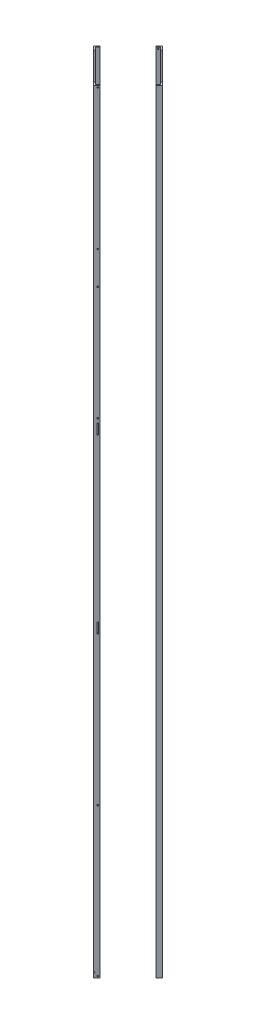
from build123d import *

# Parameters (mm, degrees)
BOSS_EXTRUDE1_DEPTH   = 2133.6
BOSS_EXTRUDE1_2_DEPTH = 2133.6
BOSS_EXTRUDE1_3_DEPTH = 2133.6
BOSS_EXTRUDE1_4_DEPTH = 2133.6
CUT_EXTRUDE1_DEPTH    = 3.175
CUT_EXTRUDE2_DEPTH    = 3.175
CUT_EXTRUDE3_DEPTH    = 3.175
CUT_EXTRUDE4_DEPTH    = 3.175
LPATTERN1_COUNT       = 2
LPATTERN1_PITCH       = 408.305
LPATTERN2_COUNT       = 2
LPATTERN2_PITCH       = 831.85
CUT_EXTRUDE5_DEPTH    = 3.175
CUT_EXTRUDE6_DEPTH    = 3.175
CUT_EXTRUDE7_DEPTH    = 3.175
CUT_EXTRUDE8_DEPTH    = 3.175
LPATTERN12_COUNT      = 2
LPATTERN12_PITCH      = 1308.1
LPATTERN13_COUNT      = 2
LPATTERN13_PITCH      = 476.25
LPATTERN16_COUNT      = 2
LPATTERN16_PITCH      = 1647.825
LPATTERN17_COUNT      = 2
LPATTERN17_PITCH      = 1333.5
LPATTERN18_COUNT      = 2
LPATTERN18_PITCH      = 1737.995
LPATTERN19_COUNT      = 2
LPATTERN19_PITCH      = 2124.075
SKETCH13_R            = 2.032
CUT_EXTRUDE9_DEPTH    = 12.225320151


with BuildPart() as part:
    # Sketch2 → Boss-Extrude1 (new body)
    with BuildSketch(Plane(origin=(0, 0, 0), x_dir=(1, 0, 0), z_dir=(0, 1, 0))):
        Polygon((0, 94.77428536), (-8.980256121, 85.794029239), (-6.735192091, 83.548965209), (0, 90.2841573), (6.735192091, 83.548965209), (8.980256121, 85.794029239), align=None)
    extrude(amount=BOSS_EXTRUDE1_DEPTH)

    # Sketch5 → Cut-Extrude2 (cut)
    with BuildSketch(Plane(origin=(-47.38714268, 0, -47.38714268), x_dir=(-0.707106781, 0, 0.707106781), z_dir=(-0.707106781, 0, -0.707106781))):
        with BuildLine():
            ThreePointArc((-57.32543986, 4.7625), (-59.07803986, 6.5151), (-60.83063986, 4.7625))
            Line((-60.83063986, 4.7625), (-57.32543986, 4.7625))
        make_face()
        with BuildLine():
            Line((-57.32543986, 4.7625), (-60.83063986, 4.7625))
            ThreePointArc((-60.83063986, 4.7625), (-59.07803986, 3.0099), (-57.32543986, 4.7625))
        make_face()
    cut_extrude2 = extrude(amount=-CUT_EXTRUDE2_DEPTH, mode=Mode.SUBTRACT)


with BuildPart() as body_2:
    # Sketch2 → Boss-Extrude1 2 (new body)
    with BuildSketch(Plane(origin=(0, 0, 0), x_dir=(1, 0, 0), z_dir=(0, 1, 0))):
        Polygon((94.741702077, 0.032583283), (85.761445956, 9.012839404), (83.516381926, 6.767775374), (90.251574017, 0.032583283), (83.516381926, -6.702608808), (85.761445956, -8.947672838), align=None)
    extrude(amount=BOSS_EXTRUDE1_2_DEPTH)

    # Sketch6 → Cut-Extrude3 (cut)
    with BuildSketch(Plane(origin=(47.38714268, 0, -47.38714268), x_dir=(-0.707106781, 0, -0.707106781), z_dir=(0.707106781, 0, -0.707106781))):
        with BuildLine():
            ThreePointArc((-57.27936014, 4.7625), (-59.03196014, 6.5151), (-60.78456014, 4.7625))
            Line((-60.78456014, 4.7625), (-57.27936014, 4.7625))
        make_face()
        with BuildLine():
            Line((-57.27936014, 4.7625), (-60.78456014, 4.7625))
            ThreePointArc((-60.78456014, 4.7625), (-59.03196014, 3.0099), (-57.27936014, 4.7625))
        make_face()
    cut_extrude3 = extrude(amount=-CUT_EXTRUDE3_DEPTH, mode=Mode.SUBTRACT)


with BuildPart() as body_3:
    # Sketch2 → Boss-Extrude1 3 (new body)
    with BuildSketch(Plane(origin=(0, 0, 0), x_dir=(1, 0, 0), z_dir=(0, 1, 0))):
        Polygon((0, -94.709118794), (8.980256121, -85.728862673), (6.735192091, -83.483798643), (0, -90.218990734), (-6.735192091, -83.483798643), (-8.980256121, -85.728862673), align=None)
    extrude(amount=BOSS_EXTRUDE1_3_DEPTH)

    # Sketch7 → Cut-Extrude4 (cut)
    with BuildSketch(Plane(origin=(47.354559397, 0, 47.354559397), x_dir=(0.707106781, 0, -0.707106781), z_dir=(0.707106781, 0, 0.707106781))):
        with BuildLine():
            ThreePointArc((-57.27936014, 4.7625), (-59.03196014, 6.5151), (-60.78456014, 4.7625))
            Line((-60.78456014, 4.7625), (-57.27936014, 4.7625))
        make_face()
        with BuildLine():
            Line((-57.27936014, 4.7625), (-60.78456014, 4.7625))
            ThreePointArc((-60.78456014, 4.7625), (-59.03196014, 3.0099), (-57.27936014, 4.7625))
        make_face()
    cut_extrude4 = extrude(amount=-CUT_EXTRUDE4_DEPTH, mode=Mode.SUBTRACT)


with BuildPart() as body_4:
    # Sketch2 → Boss-Extrude1 4 (new body)
    with BuildSketch(Plane(origin=(0, 0, 0), x_dir=(1, 0, 0), z_dir=(0, 1, 0))):
        Polygon((-94.741702077, 0.032583283), (-85.761445956, -8.947672838), (-83.516381926, -6.702608808), (-90.251574017, 0.032583283), (-83.516381926, 6.767775374), (-85.761445956, 9.012839404), align=None)
    extrude(amount=BOSS_EXTRUDE1_4_DEPTH)

    # Sketch4 → Cut-Extrude1 (cut)
    with BuildSketch(Plane(origin=(-47.354559397, 0, 47.354559397), x_dir=(0.707106781, 0, 0.707106781), z_dir=(-0.707106781, 0, 0.707106781))):
        with BuildLine():
            ThreePointArc((-60.83063986, 4.7625), (-59.07803986, 3.0099), (-57.32543986, 4.7625))
            Line((-57.32543986, 4.7625), (-60.83063986, 4.7625))
        make_face()
        with BuildLine():
            Line((-60.83063986, 4.7625), (-57.32543986, 4.7625))
            ThreePointArc((-57.32543986, 4.7625), (-59.07803986, 6.5151), (-60.83063986, 4.7625))
        make_face()
    cut_extrude1 = extrude(amount=-CUT_EXTRUDE1_DEPTH, mode=Mode.SUBTRACT)


with BuildPart() as lpattern1_tool:
    # LPattern1: Cut-Extrude1, Cut-Extrude2, Cut-Extrude3, Cut-Extrude4 ×2
    with Locations(*[(0, i * LPATTERN1_PITCH, 0) for i in range(1, LPATTERN1_COUNT)]):
        add(cut_extrude1)
        add(cut_extrude2)
        add(cut_extrude3)
        add(cut_extrude4)


with BuildPart() as part_1:
    add(part.part)

    # LPattern1: cut by lpattern1_tool
    add(lpattern1_tool.part, mode=Mode.SUBTRACT)


with BuildPart() as body_2_1:
    add(body_2.part)

    # LPattern1: cut by lpattern1_tool
    add(lpattern1_tool.part, mode=Mode.SUBTRACT)


with BuildPart() as body_3_1:
    add(body_3.part)

    # LPattern1: cut by lpattern1_tool
    add(lpattern1_tool.part, mode=Mode.SUBTRACT)


with BuildPart() as body_4_1:
    add(body_4.part)

    # LPattern1: cut by lpattern1_tool
    add(lpattern1_tool.part, mode=Mode.SUBTRACT)


with BuildPart() as lpattern2_tool:
    # LPattern2: Cut-Extrude1, Cut-Extrude2, Cut-Extrude3, Cut-Extrude4 ×2
    with Locations(*[(0, i * LPATTERN2_PITCH, 0) for i in range(1, LPATTERN2_COUNT)]):
        add(cut_extrude1)
        add(cut_extrude2)
        add(cut_extrude3)
        add(cut_extrude4)


with BuildPart() as part_2:
    add(part_1.part)

    # LPattern2: cut by lpattern2_tool
    add(lpattern2_tool.part, mode=Mode.SUBTRACT)

    # Sketch10 → Cut-Extrude7 (cut)
    with BuildSketch(Plane(origin=(-47.38714268, 0, -47.38714268), x_dir=(-0.707106781, 0, 0.707106781), z_dir=(-0.707106781, 0, -0.707106781))):
        with BuildLine():
            ThreePointArc((-60.83063986, 849.3125), (-59.07803986, 851.0651), (-57.32543986, 849.3125))
            Line((-57.32543986, 849.3125), (-60.83063986, 849.3125))
        make_face()
        with BuildLine():
            Line((-60.83063986, 849.3125), (-60.83063986, 836.6125))
            ThreePointArc((-60.83063986, 836.6125), (-59.07803986, 838.3651), (-57.32543986, 836.6125))
            Line((-57.32543986, 836.6125), (-57.32543986, 849.3125))
            Line((-57.32543986, 849.3125), (-60.83063986, 849.3125))
        make_face()
        with BuildLine():
            Line((-60.83063986, 836.6125), (-60.83063986, 823.9125))
            Line((-60.83063986, 823.9125), (-57.32543986, 823.9125))
            Line((-57.32543986, 823.9125), (-57.32543986, 836.6125))
            ThreePointArc((-57.32543986, 836.6125), (-59.07803986, 834.8599), (-60.83063986, 836.6125))
        make_face()
        with BuildLine():
            Line((-60.83063986, 823.9125), (-57.32543986, 823.9125))
            ThreePointArc((-57.32543986, 823.9125), (-59.07803986, 822.1599), (-60.83063986, 823.9125))
        make_face()
    cut_extrude7 = extrude(amount=-CUT_EXTRUDE7_DEPTH, mode=Mode.SUBTRACT)


with BuildPart() as body_2_2:
    add(body_2_1.part)

    # LPattern2: cut by lpattern2_tool
    add(lpattern2_tool.part, mode=Mode.SUBTRACT)

    # Sketch11 → Cut-Extrude8 (cut)
    with BuildSketch(Plane(origin=(47.38714268, 0, -47.38714268), x_dir=(-0.707106781, 0, -0.707106781), z_dir=(0.707106781, 0, -0.707106781))):
        with BuildLine():
            ThreePointArc((-60.78456014, 849.3125), (-59.03196014, 851.0651), (-57.27936014, 849.3125))
            Line((-57.27936014, 849.3125), (-60.78456014, 849.3125))
        make_face()
        with BuildLine():
            Line((-60.78456014, 849.3125), (-60.78456014, 836.612500003))
            ThreePointArc((-60.78456014, 836.612500003), (-59.031960138, 838.3651), (-57.27936014, 836.6125))
            Line((-57.27936014, 836.6125), (-57.27936014, 849.3125))
            Line((-57.27936014, 849.3125), (-60.78456014, 849.3125))
        make_face()
        with BuildLine():
            Line((-60.78456014, 836.612500003), (-60.78456014, 823.9125))
            Line((-60.78456014, 823.9125), (-57.27936014, 823.9125))
            Line((-57.27936014, 823.9125), (-57.27936014, 836.6125))
            ThreePointArc((-57.27936014, 836.6125), (-59.031960141, 834.8599), (-60.78456014, 836.612500003))
        make_face()
        with BuildLine():
            Line((-60.78456014, 823.9125), (-57.27936014, 823.9125))
            ThreePointArc((-57.27936014, 823.9125), (-59.03196014, 822.1599), (-60.78456014, 823.9125))
        make_face()
    cut_extrude8 = extrude(amount=-CUT_EXTRUDE8_DEPTH, mode=Mode.SUBTRACT)


with BuildPart() as body_3_2:
    add(body_3_1.part)

    # LPattern2: cut by lpattern2_tool
    add(lpattern2_tool.part, mode=Mode.SUBTRACT)

    # Sketch8 → Cut-Extrude5 (cut)
    with BuildSketch(Plane(origin=(47.354559397, 0, 47.354559397), x_dir=(0.707106781, 0, -0.707106781), z_dir=(0.707106781, 0, 0.707106781))):
        with BuildLine():
            ThreePointArc((-60.78456014, 849.3125), (-59.03196014, 851.0651), (-57.27936014, 849.3125))
            Line((-57.27936014, 849.3125), (-60.78456014, 849.3125))
        make_face()
        with BuildLine():
            Line((-60.78456014, 849.3125), (-60.78456014, 836.6125))
            ThreePointArc((-60.78456014, 836.6125), (-59.03196014, 838.3651), (-57.27936014, 836.6125))
            Line((-57.27936014, 836.6125), (-57.27936014, 849.3125))
            Line((-57.27936014, 849.3125), (-60.78456014, 849.3125))
        make_face()
        with BuildLine():
            Line((-60.78456014, 836.6125), (-60.78456014, 823.9125))
            Line((-60.78456014, 823.9125), (-57.27936014, 823.9125))
            Line((-57.27936014, 823.9125), (-57.27936014, 836.6125))
            ThreePointArc((-57.27936014, 836.6125), (-59.03196014, 834.8599), (-60.78456014, 836.6125))
        make_face()
        with BuildLine():
            ThreePointArc((-57.27936014, 823.9125), (-59.03196014, 822.1599), (-60.78456014, 823.9125))
            Line((-60.78456014, 823.9125), (-57.27936014, 823.9125))
        make_face()
    cut_extrude5 = extrude(amount=-CUT_EXTRUDE5_DEPTH, mode=Mode.SUBTRACT)


with BuildPart() as body_4_2:
    add(body_4_1.part)

    # LPattern2: cut by lpattern2_tool
    add(lpattern2_tool.part, mode=Mode.SUBTRACT)

    # Sketch9 → Cut-Extrude6 (cut)
    with BuildSketch(Plane(origin=(-47.354559397, 0, 47.354559397), x_dir=(0.707106781, 0, 0.707106781), z_dir=(-0.707106781, 0, 0.707106781))):
        with BuildLine():
            ThreePointArc((-60.83063986, 849.3125), (-59.07803986, 851.0651), (-57.32543986, 849.3125))
            Line((-57.32543986, 849.3125), (-60.83063986, 849.3125))
        make_face()
        with BuildLine():
            Line((-60.83063986, 849.3125), (-60.83063986, 836.6125))
            ThreePointArc((-60.83063986, 836.6125), (-59.07803986, 838.3651), (-57.32543986, 836.6125))
            Line((-57.32543986, 836.6125), (-57.32543986, 849.3125))
            Line((-57.32543986, 849.3125), (-60.83063986, 849.3125))
        make_face()
        with BuildLine():
            Line((-60.83063986, 836.6125), (-60.83063986, 823.9125))
            Line((-60.83063986, 823.9125), (-57.32543986, 823.9125))
            Line((-57.32543986, 823.9125), (-57.32543986, 836.6125))
            ThreePointArc((-57.32543986, 836.6125), (-59.07803986, 834.8599), (-60.83063986, 836.6125))
        make_face()
        with BuildLine():
            ThreePointArc((-57.32543986, 823.9125), (-59.07803986, 822.1599), (-60.83063986, 823.9125))
            Line((-60.83063986, 823.9125), (-57.32543986, 823.9125))
        make_face()
    cut_extrude6 = extrude(amount=-CUT_EXTRUDE6_DEPTH, mode=Mode.SUBTRACT)


with BuildPart() as lpattern12_tool:
    # LPattern12: Cut-Extrude1, Cut-Extrude2, Cut-Extrude3, Cut-Extrude4 ×2
    with Locations(*[(0, i * LPATTERN12_PITCH, 0) for i in range(1, LPATTERN12_COUNT)]):
        add(cut_extrude1)
        add(cut_extrude2)
        add(cut_extrude3)
        add(cut_extrude4)


with BuildPart() as part_3:
    add(part_2.part)

    # LPattern12: cut by lpattern12_tool
    add(lpattern12_tool.part, mode=Mode.SUBTRACT)


with BuildPart() as body_2_3:
    add(body_2_2.part)

    # LPattern12: cut by lpattern12_tool
    add(lpattern12_tool.part, mode=Mode.SUBTRACT)


with BuildPart() as body_3_3:
    add(body_3_2.part)

    # LPattern12: cut by lpattern12_tool
    add(lpattern12_tool.part, mode=Mode.SUBTRACT)


with BuildPart() as body_4_3:
    add(body_4_2.part)

    # LPattern12: cut by lpattern12_tool
    add(lpattern12_tool.part, mode=Mode.SUBTRACT)


with BuildPart() as lpattern13_tool:
    # LPattern13: Cut-Extrude5, Cut-Extrude6, Cut-Extrude7, Cut-Extrude8 ×2
    with Locations(*[(0, i * LPATTERN13_PITCH, 0) for i in range(1, LPATTERN13_COUNT)]):
        add(cut_extrude5)
        add(cut_extrude6)
        add(cut_extrude7)
        add(cut_extrude8)


with BuildPart() as part_4:
    add(part_3.part)

    # LPattern13: cut by lpattern13_tool
    add(lpattern13_tool.part, mode=Mode.SUBTRACT)


with BuildPart() as body_2_4:
    add(body_2_3.part)

    # LPattern13: cut by lpattern13_tool
    add(lpattern13_tool.part, mode=Mode.SUBTRACT)


with BuildPart() as body_3_4:
    add(body_3_3.part)

    # LPattern13: cut by lpattern13_tool
    add(lpattern13_tool.part, mode=Mode.SUBTRACT)


with BuildPart() as body_4_4:
    add(body_4_3.part)

    # LPattern13: cut by lpattern13_tool
    add(lpattern13_tool.part, mode=Mode.SUBTRACT)


with BuildPart() as lpattern16_tool:
    # LPattern16: Cut-Extrude1, Cut-Extrude2, Cut-Extrude3, Cut-Extrude4 ×2
    with Locations(*[(0, i * LPATTERN16_PITCH, 0) for i in range(1, LPATTERN16_COUNT)]):
        add(cut_extrude1)
        add(cut_extrude2)
        add(cut_extrude3)
        add(cut_extrude4)


with BuildPart() as part_5:
    add(part_4.part)

    # LPattern16: cut by lpattern16_tool
    add(lpattern16_tool.part, mode=Mode.SUBTRACT)


with BuildPart() as body_2_5:
    add(body_2_4.part)

    # LPattern16: cut by lpattern16_tool
    add(lpattern16_tool.part, mode=Mode.SUBTRACT)


with BuildPart() as body_3_5:
    add(body_3_4.part)

    # LPattern16: cut by lpattern16_tool
    add(lpattern16_tool.part, mode=Mode.SUBTRACT)


with BuildPart() as body_4_5:
    add(body_4_4.part)

    # LPattern16: cut by lpattern16_tool
    add(lpattern16_tool.part, mode=Mode.SUBTRACT)


with BuildPart() as lpattern17_tool:
    # LPattern17: Cut-Extrude1, Cut-Extrude2, Cut-Extrude3, Cut-Extrude4 ×2
    with Locations(*[(0, i * LPATTERN17_PITCH, 0) for i in range(1, LPATTERN17_COUNT)]):
        add(cut_extrude1)
        add(cut_extrude2)
        add(cut_extrude3)
        add(cut_extrude4)


with BuildPart() as part_6:
    add(part_5.part)

    # LPattern17: cut by lpattern17_tool
    add(lpattern17_tool.part, mode=Mode.SUBTRACT)


with BuildPart() as body_2_6:
    add(body_2_5.part)

    # LPattern17: cut by lpattern17_tool
    add(lpattern17_tool.part, mode=Mode.SUBTRACT)


with BuildPart() as body_3_6:
    add(body_3_5.part)

    # LPattern17: cut by lpattern17_tool
    add(lpattern17_tool.part, mode=Mode.SUBTRACT)


with BuildPart() as body_4_6:
    add(body_4_5.part)

    # LPattern17: cut by lpattern17_tool
    add(lpattern17_tool.part, mode=Mode.SUBTRACT)


with BuildPart() as lpattern18_tool:
    # LPattern18: Cut-Extrude1, Cut-Extrude2, Cut-Extrude3, Cut-Extrude4 ×2
    with Locations(*[(0, i * LPATTERN18_PITCH, 0) for i in range(1, LPATTERN18_COUNT)]):
        add(cut_extrude1)
        add(cut_extrude2)
        add(cut_extrude3)
        add(cut_extrude4)


with BuildPart() as part_7:
    add(part_6.part)

    # LPattern18: cut by lpattern18_tool
    add(lpattern18_tool.part, mode=Mode.SUBTRACT)


with BuildPart() as body_2_7:
    add(body_2_6.part)

    # LPattern18: cut by lpattern18_tool
    add(lpattern18_tool.part, mode=Mode.SUBTRACT)


with BuildPart() as body_3_7:
    add(body_3_6.part)

    # LPattern18: cut by lpattern18_tool
    add(lpattern18_tool.part, mode=Mode.SUBTRACT)


with BuildPart() as body_4_7:
    add(body_4_6.part)

    # LPattern18: cut by lpattern18_tool
    add(lpattern18_tool.part, mode=Mode.SUBTRACT)


with BuildPart() as lpattern19_tool:
    # LPattern19: Cut-Extrude1, Cut-Extrude2, Cut-Extrude3, Cut-Extrude4 ×2
    with Locations(*[(0, i * LPATTERN19_PITCH, 0) for i in range(1, LPATTERN19_COUNT)]):
        add(cut_extrude1)
        add(cut_extrude2)
        add(cut_extrude3)
        add(cut_extrude4)


with BuildPart() as part_8:
    add(part_7.part)

    # LPattern19: cut by lpattern19_tool
    add(lpattern19_tool.part, mode=Mode.SUBTRACT)


with BuildPart() as body_2_8:
    add(body_2_7.part)

    # LPattern19: cut by lpattern19_tool
    add(lpattern19_tool.part, mode=Mode.SUBTRACT)


with BuildPart() as body_3_8:
    add(body_3_7.part)

    # LPattern19: cut by lpattern19_tool
    add(lpattern19_tool.part, mode=Mode.SUBTRACT)

    # Sketch13 → Cut-Extrude9 (cut, through all)
    with BuildSketch(Plane(origin=(0, 0, 83.483798643), x_dir=(-1, 0, 0), z_dir=(0, 0, -1))):
        with Locations((0, 13.5255)):
            Circle(SKETCH13_R)
    extrude(amount=-CUT_EXTRUDE9_DEPTH, mode=Mode.SUBTRACT)


with BuildPart() as body_4_8:
    add(body_4_7.part)

    # LPattern19: cut by lpattern19_tool
    add(lpattern19_tool.part, mode=Mode.SUBTRACT)


solid = Compound([part_8.part, body_2_8.part, body_3_8.part, body_4_8.part])
